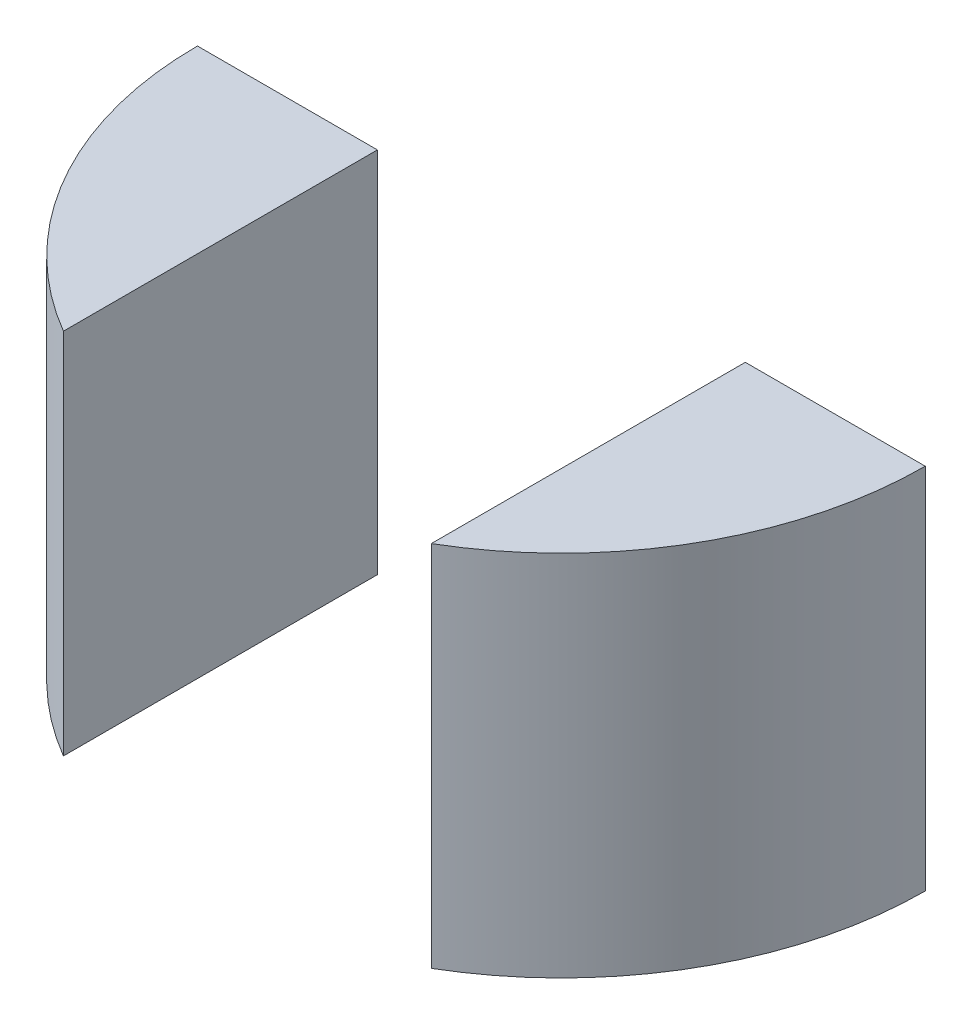
from build123d import *

# Parameters (mm, degrees)
SKETCH1_R           = 5.025
BOSS_EXTRUDE1_DEPTH = 5.08
SKETCH2_W           = 277.946121386
SKETCH2_H           = 253.043274965
CUT_EXTRUDE1_DEPTH  = 5.08
SKETCH3_W           = 5.08
SKETCH3_H           = 5.08
CUT_EXTRUDE2_DEPTH  = 10


with BuildPart() as part:
    # Sketch1 → Boss-Extrude1 (new body)
    with BuildSketch(Plane(origin=(0, 0, 0), x_dir=(1, 0, 0), z_dir=(0, 1, 0))):
        Circle(SKETCH1_R)
    extrude(amount=BOSS_EXTRUDE1_DEPTH)

    # Sketch2 → Cut-Extrude1 (cut)
    with BuildSketch(Plane(origin=(0, 5.08, 0), x_dir=(1, 0, 0), z_dir=(0, 1, 0))):
        with Locations((-133.948060693, 126.521637483)):
            Rectangle(SKETCH2_W, SKETCH2_H)
    extrude(amount=-CUT_EXTRUDE1_DEPTH, mode=Mode.SUBTRACT)

    # Sketch3 → Cut-Extrude2 (cut)
    with BuildSketch(Plane(origin=(0, 0, 0), x_dir=(-1, 0, 0), z_dir=(0, 0, -1))):
        with Locations((0, 2.54)):
            Rectangle(SKETCH3_W, SKETCH3_H)
    extrude(amount=-CUT_EXTRUDE2_DEPTH, mode=Mode.SUBTRACT)


solid = part.part
